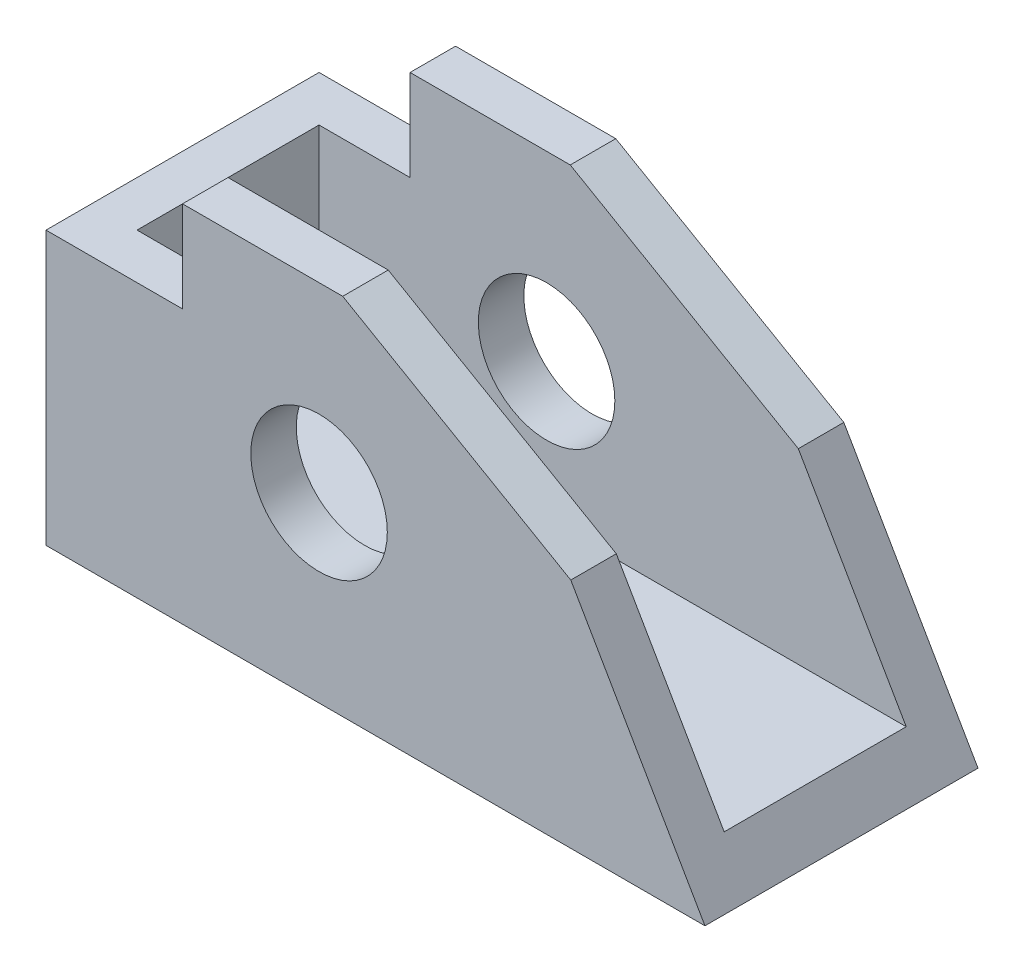
from build123d import *

# Parameters (mm, degrees)
SKETCH1_W                   = 91.948
SKETCH1_H                   = 38.1
REC_1_5_X_2_0_X_3_62_DEPTH  = 50.8
SKETCH_1_0_X_1_75_W         = 25.4
SKETCH_1_0_X_1_75_H         = 44.45
REC_1_0_X_1_75_X_3_37_DEPTH = 85.598
SKETCH_0_5_X_0_75_W         = 19.05
SKETCH_0_5_X_0_75_H         = 12.7
REC_0_5_X_0_75_X_1_5_DEPTH  = 39.1
CUT_EXTRUDE4_DEPTH          = 39.1
SKETCH8_R                   = 9.525
CUT_EXTRUDE5_DEPTH          = 39.1


with BuildPart() as part:
    # Sketch1 → Rec : 1.5 x 2.0 x 3.62 (new body)
    with BuildSketch(Plane(origin=(0, 0, 0), x_dir=(1, 0, 0), z_dir=(0, 1, 0))):
        with Locations((-44.377428571, 25.7175)):
            Rectangle(SKETCH1_W, SKETCH1_H)
    extrude(amount=REC_1_5_X_2_0_X_3_62_DEPTH)

    # 1.0 x 1.75 → Rec : 1.0 x 1.75 x 3.37 (cut)
    with BuildSketch(Plane(origin=(1.596571429, 0, 0), x_dir=(0, 0, -1), z_dir=(1, 0, 0))):
        with Locations((25.7175, 28.575)):
            Rectangle(SKETCH_1_0_X_1_75_W, SKETCH_1_0_X_1_75_H)
    extrude(amount=-REC_1_0_X_1_75_X_3_37_DEPTH, mode=Mode.SUBTRACT)

    # 0.5 x 0.75 → Rec : 0.5 x 0.75 x 1.5 (cut, through all)
    with BuildSketch(Plane.XY.offset(-6.6675)):
        with Locations((-80.826428571, 44.45)):
            Rectangle(SKETCH_0_5_X_0_75_W, SKETCH_0_5_X_0_75_H)
    extrude(amount=-REC_0_5_X_0_75_X_1_5_DEPTH, mode=Mode.SUBTRACT)

    # Sketch7 → Cut-Extrude4 (cut, through all)
    with BuildSketch(Plane.XY.offset(-6.6675)):
        Polygon((1.596571429, 0), (-17.124519084, 32.42587994), (-48.949428571, 50.8), (1.596571429, 50.8), align=None)
    extrude(amount=-CUT_EXTRUDE4_DEPTH, mode=Mode.SUBTRACT)

    # Sketch8 → Cut-Extrude5 (cut, through all)
    with BuildSketch(Plane.XY.offset(-6.6675)):
        with Locations((-52.251428571, 25.4)):
            Circle(SKETCH8_R)
    extrude(amount=-CUT_EXTRUDE5_DEPTH, mode=Mode.SUBTRACT)


solid = part.part
